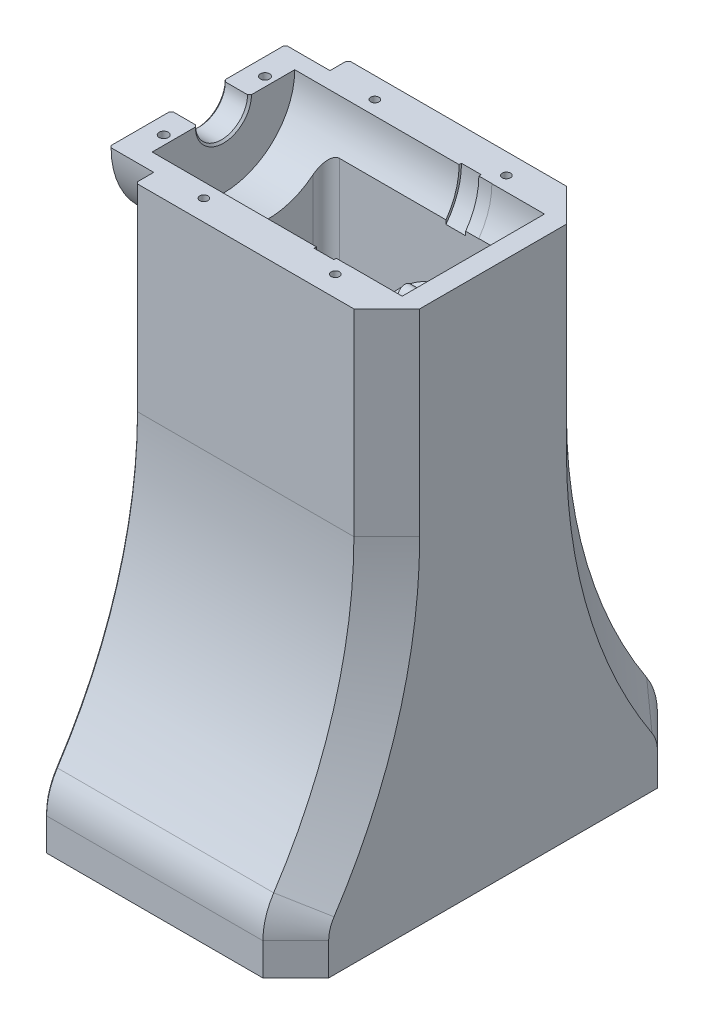
from build123d import *

# Parameters (mm, degrees)
TRIM_START                     = -35.052
TRIM_MOTOR_DEPTH               = 14.208
HOUSING_START                  = 8.6106
HOUSING_DEPTH                  = 48.514
SKETCH4_R                      = 17.018
HOUSING_FRONT_BOSS_DEPTH       = 8.6106
CHAMFER1_SIZE                  = 6.35
SKETCH9_R                      = 0.889
PINS_DEPTH                     = 21.5232
PINS_DEPTH_BACK                = 104.124
CHAMFER2_SIZE                  = 0.381
CUT_EXTRUDE2_DEPTH             = 104.124
CUT_EXTRUDE4_START             = -30.48
CUT_EXTRUDE4_DEPTH             = 73.6440001
CUT_EXTRUDE3_DEPTH             = 22.86
FILLET2_R                      = 3.81
M5X0_8_TAPPED_HOLE1_AT_2_COUNT = 2
M5X0_8_TAPPED_HOLE1_AT_2_PITCH = 31.75
C_BORES_START                  = 4.572
SKETCH13_R                     = 2.54
C_BORES_DEPTH                  = 16.9512
SKETCH15_W                     = 1.1
SKETCH15_H                     = 107.696
M2_CLEARANCE_HOLE1_AT_2_COUNT  = 2
M2_CLEARANCE_HOLE1_AT_2_PITCH  = 25.4
M2X0_4_TAPPED_HOLE1_AT_2_COUNT = 2
M2X0_4_TAPPED_HOLE1_AT_2_PITCH = 25.4
CUT_EXTRUDE5_DEPTH             = 10.16
CHAMFER3_SIZE                  = 8.89
CHAMFER3_SIZE2                 = 5.132643893
FILLET3_R                      = 2.54


with BuildPart() as part:
    # Sketch1 → REVOLVE MOTOR (revolve)
    with BuildSketch(Plane.XY):
        Polygon((0, 0), (0, 5.0292), (5.0546, 5.0292), (5.0546, 13.7668), (36.8046, 13.7668), (36.8046, 14.224), (40.6146, 14.224), (40.6146, 13.7668), (43.1546, 13.7668), (43.1546, 13.7414), (53.3146, 13.7414), (53.3146, 0), align=None)
    revolve(axis=Axis((53.3146, 0, 0), (-1, 0, 0)))

    # Sketch2 → TRIM MOTOR (cut, through all)
    with BuildSketch(Plane.ZY.offset(-5.0546).offset(TRIM_START)):
        with BuildLine():
            Line((-1.4224, -14.6304), (-1.4224, -12.9032))
            ThreePointArc((-1.4224, -12.9032), (0, -11.4808), (1.4224, -12.9032))
            Line((1.4224, -12.9032), (1.4224, -14.6304))
            ThreePointArc((1.4224, -14.6304), (0, -16.0528), (-1.4224, -14.6304))
        make_face()
        with BuildLine():
            Line((1.4224, 14.6304), (1.4224, 12.9032))
            ThreePointArc((1.4224, 12.9032), (0, 11.4808), (-1.4224, 12.9032))
            Line((-1.4224, 12.9032), (-1.4224, 14.6304))
            ThreePointArc((-1.4224, 14.6304), (0, 16.0528), (1.4224, 14.6304))
        make_face()
    extrude(amount=-TRIM_MOTOR_DEPTH, mode=Mode.SUBTRACT)


with BuildPart() as body_2:
    # Sketch3 → HOUSING (new body)
    with BuildSketch(Plane(origin=(0, 0, 0), x_dir=(0, 0, -1), z_dir=(1, 0, 0)).offset(HOUSING_START)):
        with BuildLine():
            Line((0, -103.124), (38.1, -103.124))
            Line((38.1, -103.124), (38.1, -96.892084637))
            ThreePointArc((38.1, -96.892084637), (37.567853113, -93.254317378), (36.016007775, -89.92140469))
            ThreePointArc((36.016007775, -89.92140469), (24.479284545, -65.143876741), (20.5232, -38.1))
            Line((20.5232, -38.1), (20.5232, 0))
            ThreePointArc((20.5232, 0), (14.512093892, 14.512093892), (0, 20.5232))
            Line((0, 20.5232), (0, -103.124))
        make_face()
    extrude(amount=HOUSING_DEPTH)

    # Sketch4 → HOUSING FRONT BOSS (add)
    with BuildSketch(Plane.ZY.offset(-8.6106)):
        Circle(SKETCH4_R)
    extrude(amount=HOUSING_FRONT_BOSS_DEPTH)

    # SUBTRACT MOTOR: cut part
    add(part.part, mode=Mode.SUBTRACT)

    # Chamfer1
    chamfer1_edges = [body_2.edges().sort_by_distance(p)[0] for p in [
        (57.1246, -100.008042319, -38.1),
        (57.1246, -19.05, -20.5232),
        (57.1246, -65.143876741, -24.479284545),
        (57.1246, -93.254317378, -37.567853113),
        (57.1246, 14.512093892, -14.512093892),
    ]]
    chamfer(chamfer1_edges, length=CHAMFER1_SIZE)

    # Sketch9 → PINS (cut, two sides)
    with BuildSketch(Plane(origin=(0, 0, 0), x_dir=(1, 0, 0), z_dir=(0, 1, 0))) as pins_sk:
        with Locations((3.302, 9.779)):
            Circle(SKETCH9_R)
        with Locations((3.302, -9.779)):
            Circle(SKETCH9_R)
    extrude(amount=PINS_DEPTH, mode=Mode.SUBTRACT)
    extrude(pins_sk.sketch, amount=-PINS_DEPTH_BACK, mode=Mode.SUBTRACT)

    # Chamfer2
    chamfer2_edges = [body_2.edges().sort_by_distance(p)[0] for p in [
        (8.6106, -93.254317378, -37.567853113),
        (8.6106, -100.008042319, -38.1),
        (8.6106, -19.05, -20.5232),
        (0, 0, -17.018),
        (8.6106, -65.143876741, -24.479284545),
        (0, -5.0292, 0),
        (5.0546, -5.0292, 0),
        (8.6106, 14.512093892, -14.512093892),
    ]]
    chamfer(chamfer2_edges, length=CHAMFER2_SIZE)


with BuildPart() as body_2_2:
    # Split1: the piece on the far side of the plane
    add(body_2.part)
    split(bisect_by=Plane.ZX, keep=Keep.BOTTOM)

    # Sketch5 → Cut-Extrude2 (cut, through all)
    with BuildSketch(Plane(origin=(0, 0, 0), x_dir=(1, 0, 0), z_dir=(0, 1, 0))):
        with BuildLine():
            Line((13.6906, 0), (37.5666, 0))
            Line((37.5666, 0), (37.5666, 8.6868))
            ThreePointArc((37.5666, 8.6868), (36.822651224, 10.482851224), (35.0266, 11.2268))
            Line((35.0266, 11.2268), (16.2306, 11.2268))
            ThreePointArc((16.2306, 11.2268), (14.434548776, 10.482851224), (13.6906, 8.6868))
            Line((13.6906, 8.6868), (13.6906, 0))
        make_face()
    extrude(amount=-CUT_EXTRUDE2_DEPTH, mode=Mode.SUBTRACT)

    # Sketch7 → Cut-Extrude4 (cut, through all)
    with BuildSketch(Plane(origin=(0, 0, 0), x_dir=(1, 0, 0), z_dir=(0, 1, 0)).offset(CUT_EXTRUDE4_START)):
        with BuildLine():
            Line((35.0266, 11.2268), (49.5046, 11.2268))
            ThreePointArc((49.5046, 11.2268), (51.300651224, 10.482851224), (52.0446, 8.6868))
            Line((52.0446, 8.6868), (52.0446, 0))
            Line((52.0446, 0), (35.0266, 0))
            Line((35.0266, 0), (35.0266, 11.2268))
        make_face()
    extrude(amount=-CUT_EXTRUDE4_DEPTH, mode=Mode.SUBTRACT)

    # Sketch6 → Cut-Extrude3 (cut)
    with BuildSketch(Plane(origin=(0, 0, 0), x_dir=(1, 0, 0), z_dir=(0, 1, 0))):
        with BuildLine():
            Line((35.0266, 11.2268), (50.7746, 11.2268))
            ThreePointArc((50.7746, 11.2268), (52.570651224, 10.482851224), (53.3146, 8.6868))
            Line((53.3146, 8.6868), (53.3146, 7.4168))
            ThreePointArc((53.3146, 7.4168), (52.570651224, 5.620748776), (50.7746, 4.8768))
            Line((50.7746, 4.8768), (35.0266, 4.8768))
            Line((35.0266, 4.8768), (35.0266, 11.2268))
        make_face()
    extrude(amount=-CUT_EXTRUDE3_DEPTH, mode=Mode.SUBTRACT)

    # Fillet2
    fillet2_edges = [body_2_2.edges().sort_by_distance(p)[0] for p in [
        (37.5666, -18.110924295, -4.8768),
    ]]
    fillet(fillet2_edges, radius=FILLET2_R)

    # Sketch12 → M5x0.8 Tapped Hole1 (revolve, cut)
    with BuildSketch(Plane(origin=(17.7546, -103.124, -30.48), x_dir=(0, 0, -1), z_dir=(1, 0, 0))):
        Polygon((0, 0), (0, 16.2478073), (2.1, 14.986), (2.1, 0), align=None)
    m5x0_8_tapped_hole1 = revolve(axis=Axis((17.7546, -109.474, -30.48), (0, 1, 0)), mode=Mode.SUBTRACT)

    # M5x0.8 Tapped Hole1 at 2: M5x0.8 Tapped Hole1 ×2
    with Locations(*[(i * M5X0_8_TAPPED_HOLE1_AT_2_PITCH, 0, 0) for i in range(1, M5X0_8_TAPPED_HOLE1_AT_2_COUNT)]):
        add(m5x0_8_tapped_hole1, mode=Mode.SUBTRACT)

    # Sketch17 → M2x0.4 Tapped Hole1 (revolve, cut)
    with BuildSketch(Plane(origin=(17.78, 0, -16.51), x_dir=(0, 0, 1), z_dir=(1, 0, 0))):
        Polygon((0, 0), (0, 14.450688495), (0.8, 13.97), (0.8, 0), align=None)
    m2x0_4_tapped_hole1 = revolve(axis=Axis((17.78, 6.35, -16.51), (0, -1, 0)), mode=Mode.SUBTRACT)

    # M2x0.4 Tapped Hole1 at 2: M2x0.4 Tapped Hole1 ×2
    with Locations(*[(i * M2X0_4_TAPPED_HOLE1_AT_2_PITCH, 0, 0) for i in range(1, M2X0_4_TAPPED_HOLE1_AT_2_COUNT)]):
        add(m2x0_4_tapped_hole1, mode=Mode.SUBTRACT)

    # Sketch18 → Cut-Extrude5 (cut)
    with BuildSketch(Plane.XY.offset(-11.2268)):
        Polygon((25.7556, -54.864), (39.9796, -54.864), (39.9796, -91.694), (38.2016, -91.694), (38.2016, -103.124), (27.5336, -103.124), (27.5336, -91.694), (25.7556, -91.694), align=None)
    extrude(amount=-CUT_EXTRUDE5_DEPTH, mode=Mode.SUBTRACT)

    # Chamfer3
    chamfer3_edges = [body_2_2.edges().sort_by_distance(p)[0] for p in [
        (32.8676, -54.864, -21.3868),
    ]]
    chamfer3_side = [body_2_2.faces().sort_by_distance(p)[0] for p in [
        (32.8676, -77.835013986, -21.3868),
    ]]
    chamfer(chamfer3_edges, length=CHAMFER3_SIZE, length2=CHAMFER3_SIZE2, reference=chamfer3_side[0])

    # Fillet3
    fillet3_edges = [body_2_2.edges().sort_by_distance(p)[0] for p in [
        (38.2016, -97.409, -21.3868),
        (27.5336, -97.409, -21.3868),
        (32.8676, -54.864, -11.2268),
        (32.8676, -63.754, -21.3868),
        (32.8676, -54.864, -16.254156107),
    ]]
    fillet(fillet3_edges, radius=FILLET3_R)

    # Mirror1: body 2 2 across plane


with BuildPart() as body_2_1:
    add(body_2.part)

    # Split1
    split(bisect_by=Plane.ZX, keep=Keep.TOP)

    # Sketch13 → C'BORES (cut, through all)
    with BuildSketch(Plane(origin=(0, 0, 0), x_dir=(1, 0, 0), z_dir=(0, 1, 0)).offset(C_BORES_START)):
        with Locations((17.78, 16.51)):
            Circle(SKETCH13_R)
        with Locations((43.18, 16.51)):
            Circle(SKETCH13_R)
    extrude(amount=C_BORES_DEPTH, mode=Mode.SUBTRACT)

    # Sketch15 → M2 Clearance Hole1 (revolve, cut)
    with BuildSketch(Plane(origin=(17.78, 4.572, -16.51), x_dir=(0, 0, 1), z_dir=(1, 0, 0))):
        with Locations((0.55, 53.848)):
            Rectangle(SKETCH15_W, SKETCH15_H)
    m2_clearance_hole1 = revolve(axis=Axis((17.78, 10.922, -16.51), (0, -1, 0)), mode=Mode.SUBTRACT)

    # M2 Clearance Hole1 at 2: M2 Clearance Hole1 ×2
    with Locations(*[(i * M2_CLEARANCE_HOLE1_AT_2_PITCH, 0, 0) for i in range(1, M2_CLEARANCE_HOLE1_AT_2_COUNT)]):
        add(m2_clearance_hole1, mode=Mode.SUBTRACT)

    # Mirror1 2: body 2 across plane


with BuildPart() as body_2_2_1:
    add(body_2_2.part)
    add(body_2_2.part.mirror(Plane.XY))


with BuildPart() as body_2_3:
    add(body_2_1.part)
    add(body_2_1.part.mirror(Plane.XY))


solid = body_2_2_1.part
